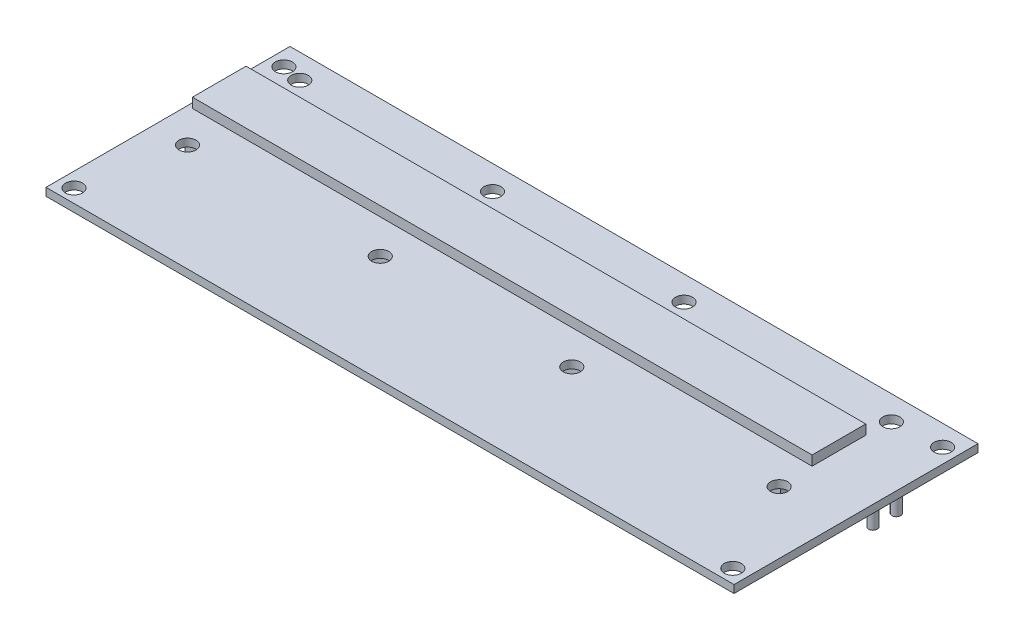
from build123d import *

# Parameters (mm, degrees)
SKETCH_1_W          = 141
SKETCH_1_H          = 50
EXTRUDE_1_DEPTH     = 1.6
SKETCH_2_R          = 1.75
CUT_EXTRUDE_1_DEPTH = 10
SKETCH_3_R          = 1.75
CUT_EXTRUDE_2_DEPTH = 10
SKETCH_4_R          = 1.234132003
EXTRUDE_2_DEPTH     = 5
SKETCH_7_W          = 122
SKETCH_7_H          = 10
EXTRUDE_3_DEPTH     = 11
SKETCH_8_W          = 127
SKETCH_8_H          = 11
EXTRUDE_4_DEPTH     = 2
SKETCH_6_R          = 0.888976415
EXTRUDE_5_DEPTH     = 5
SKETCH_9_W          = 6.5
SKETCH_9_H          = 10
CUT_EXTRUDE_3_DEPTH = 11


with BuildPart() as part:
    # 草图1 → 凸台-拉伸1 (new body)
    with BuildSketch(Plane(origin=(0, 0, 0), x_dir=(1, 0, 0), z_dir=(0, 1, 0))):
        Rectangle(SKETCH_1_W, SKETCH_1_H)
    extrude(amount=EXTRUDE_1_DEPTH)

    # 草图2 → 切除-拉伸1 (cut)
    with BuildSketch(Plane(origin=(0, 1.6, 0), x_dir=(1, 0, 0), z_dir=(0, 1, 0))):
        with Locations((-67.5, -22.25)):
            Circle(SKETCH_2_R)
        with Locations((-67.5, 20.75)):
            Circle(SKETCH_2_R)
        with Locations((67.5, 20.75)):
            Circle(SKETCH_2_R)
        with Locations((67.5, -22.25)):
            Circle(SKETCH_2_R)
    extrude(amount=-CUT_EXTRUDE_1_DEPTH, mode=Mode.SUBTRACT)

    # 草图3 → 切除-拉伸2 (cut)
    with BuildSketch(Plane(origin=(0, 1.6, 0), x_dir=(1, 0, 0), z_dir=(0, 1, 0))):
        with Locations((-63.5, 20)):
            Circle(SKETCH_3_R)
        with Locations((-24, 20)):
            Circle(SKETCH_3_R)
        with Locations((-63.5, -3)):
            Circle(SKETCH_3_R)
        with Locations((-24, -3)):
            Circle(SKETCH_3_R)
        with Locations((15.25, -3)):
            Circle(SKETCH_3_R)
        with Locations((57.75, -3)):
            Circle(SKETCH_3_R)
        with Locations((15.25, 20)):
            Circle(SKETCH_3_R)
        with Locations((57.75, 20)):
            Circle(SKETCH_3_R)
    extrude(amount=-CUT_EXTRUDE_2_DEPTH, mode=Mode.SUBTRACT)

    # 草图4 → 凸台-拉伸2 (add)
    with BuildSketch(Plane(origin=(0, 0, 0), x_dir=(1, 0, 0), z_dir=(0, 1, 0))):
        with Locations((-47.078898204, 20)):
            Circle(SKETCH_4_R)
        with Locations((-43.75, 20)):
            Circle(SKETCH_4_R)
        with Locations((-40.421101796, 20)):
            Circle(SKETCH_4_R)
    extrude(amount=-EXTRUDE_2_DEPTH)

    # 草图7 → 凸台-拉伸3 (add)
    with BuildSketch(Plane.XZ):
        with Locations((-7.5, -6.5)):
            Rectangle(SKETCH_7_W, SKETCH_7_H)
    extrude(amount=EXTRUDE_3_DEPTH)

    # 草图8 → 凸台-拉伸4 (add)
    with BuildSketch(Plane(origin=(0, 1.6, 0), x_dir=(1, 0, 0), z_dir=(0, 1, 0))):
        with Locations((-6, 9.5)):
            Rectangle(SKETCH_8_W, SKETCH_8_H)
    extrude(amount=EXTRUDE_4_DEPTH)

    # 草图6 → 凸台-拉伸5 (add)
    with BuildSketch(Plane(origin=(0, 0, 0), x_dir=(1, 0, 0), z_dir=(0, 1, 0))):
        with Locations((67.875178123, 10.882897677)):
            Circle(SKETCH_6_R)
        with Locations((67.875178123, 6.093097389)):
            Circle(SKETCH_6_R)
    extrude(amount=-EXTRUDE_5_DEPTH)

    # 草图9 → 切除-拉伸3 (cut)
    with BuildSketch(Plane.XZ.offset(11)):
        with Locations((-55.25, -6.5)):
            Rectangle(SKETCH_9_W, SKETCH_9_H)
    extrude(amount=-CUT_EXTRUDE_3_DEPTH, mode=Mode.SUBTRACT)


solid = part.part
